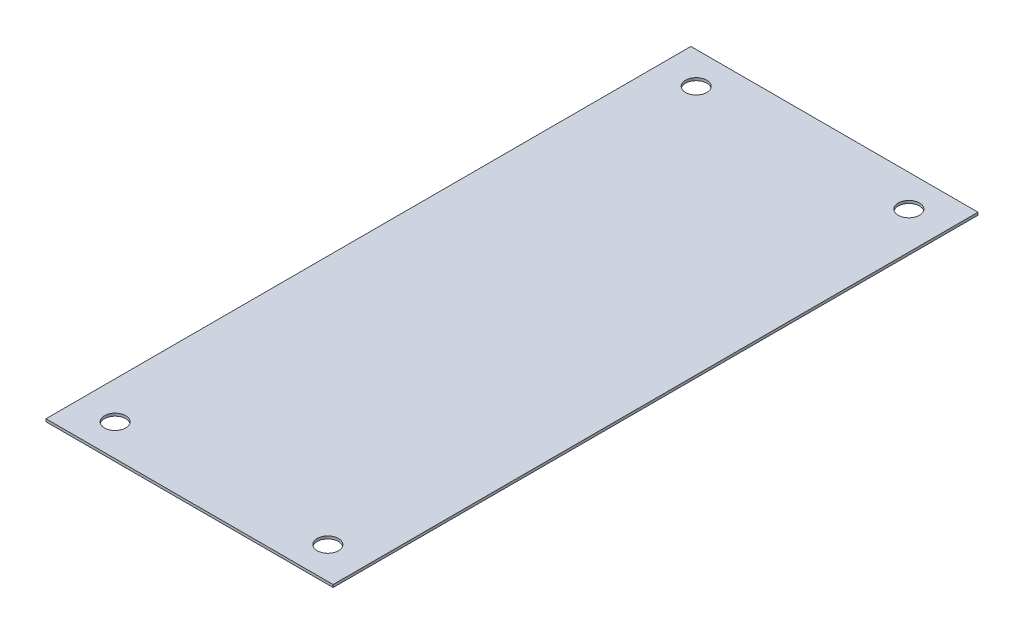
from build123d import *

# Parameters (mm, degrees)
SKETCH1_W                  = 342.9
SKETCH1_H                  = 770.128
BOSS_EXTRUDE1_DEPTH        = 3.175
F_1_1_DIAMETER_HOLE1_D     = 25.4
F_1_1_DIAMETER_HOLE1_DEPTH = 20.574
F_1_1_DIAMETER_HOLE1_TIP   = 7.630929862


with BuildPart() as part:
    # Sketch1 → Boss-Extrude1 (new body)
    with BuildSketch(Plane(origin=(0, 0, 0), x_dir=(1, 0, 0), z_dir=(0, 1, 0))):
        with Locations((171.45, 385.064)):
            Rectangle(SKETCH1_W, SKETCH1_H)
    extrude(amount=BOSS_EXTRUDE1_DEPTH)

    # 1 (1) Diameter Hole1
    with Locations(Plane(origin=(0, 3.175, 0), x_dir=(-1, 0, 0), z_dir=(0, 1, 0))):
        with Locations((-44.45, -38.1), (-44.45, -732.028), (-298.45, -732.028), (-298.45, -38.1)):
            Hole(F_1_1_DIAMETER_HOLE1_D / 2, depth=F_1_1_DIAMETER_HOLE1_DEPTH)
            with Locations((0, 0, -(F_1_1_DIAMETER_HOLE1_DEPTH + F_1_1_DIAMETER_HOLE1_TIP / 2))):  # 118° drill point
                Cone(0, F_1_1_DIAMETER_HOLE1_D / 2, F_1_1_DIAMETER_HOLE1_TIP, mode=Mode.SUBTRACT)


solid = part.part
